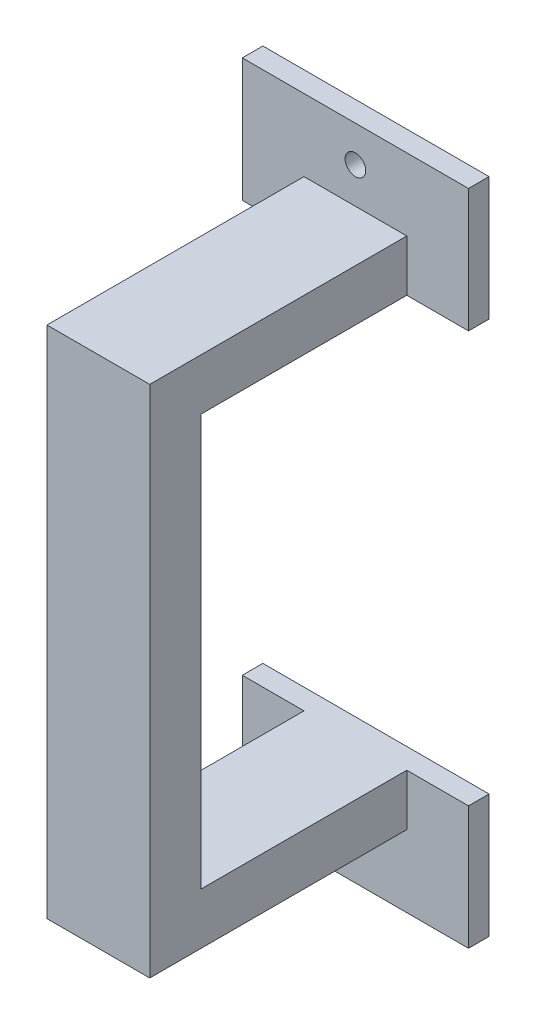
from build123d import *

# Parameters (mm, degrees)
BOSS_EXTRUDE1_DEPTH = 12.7
SKETCH3_W           = 27.94
SKETCH3_H           = 15.24
SKETCH3_R           = 1.27
BOSS_EXTRUDE2_DEPTH = 2.54


with BuildPart() as part:
    # Sketch2 → Boss-Extrude1 (new body)
    with BuildSketch(Plane(origin=(0, 0, 0), x_dir=(0, 0, -1), z_dir=(1, 0, 0))):
        Polygon((0, 44.0961272), (-31.75, 44.0961272), (-31.75, -19.4038728), (0, -19.4038728), (0, -13.0538728), (-25.4, -13.0538728), (-25.4, 37.7461272), (0, 37.7461272), align=None)
    extrude(amount=BOSS_EXTRUDE1_DEPTH)

    # Sketch3 → Boss-Extrude2 (add)
    with BuildSketch(Plane(origin=(0, 0, 0), x_dir=(-1, 0, 0), z_dir=(0, 0, -1))):
        with Locations((-6.35, 45.3661272)):
            Rectangle(SKETCH3_W, SKETCH3_H)
        with Locations((-6.35, 48.5411272)):
            Circle(SKETCH3_R, mode=Mode.SUBTRACT)
        with Locations((-6.35, -20.6738728)):
            Rectangle(SKETCH3_W, SKETCH3_H)
        with Locations((-6.35, -23.8488728)):
            Circle(SKETCH3_R, mode=Mode.SUBTRACT)
    extrude(amount=BOSS_EXTRUDE2_DEPTH)


solid = part.part
